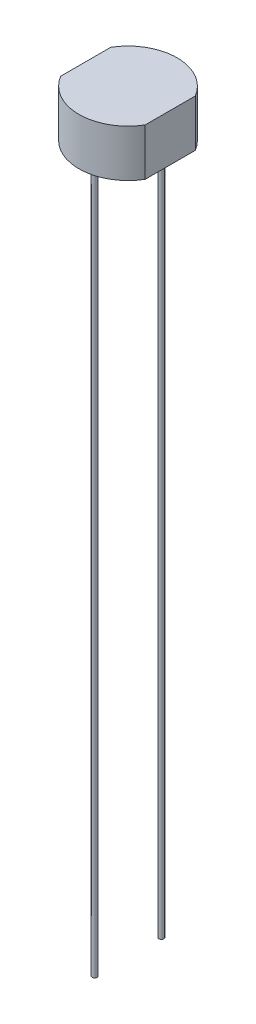
from build123d import *

# Parameters (mm, degrees)
BOSS_EXTRUDE1_DEPTH = 2.4
SKETCH2_R           = 0.125
BOSS_EXTRUDE2_DEPTH = 36


with BuildPart() as part:
    # Sketch1 → Boss-Extrude1 (new body)
    with BuildSketch(Plane(origin=(0, 0, 0), x_dir=(1, 0, 0), z_dir=(0, 1, 0))):
        with BuildLine():
            Line((-2.15, 1.275735082), (-2.15, -1.275735082))
            ThreePointArc((-2.15, -1.275735082), (0, -2.5), (2.15, -1.275735082))
            Line((2.15, -1.275735082), (2.15, 1.275735082))
            ThreePointArc((2.15, 1.275735082), (0, 2.5), (-2.15, 1.275735082))
        make_face()
    extrude(amount=BOSS_EXTRUDE1_DEPTH)

    # Sketch2 → Boss-Extrude2 (add)
    with BuildSketch(Plane(origin=(0, 0, 0), x_dir=(1, 0, 0), z_dir=(0, 1, 0))):
        with Locations((0, 1.7)):
            Circle(SKETCH2_R)
        with Locations((0, -1.7)):
            Circle(SKETCH2_R)
    extrude(amount=-BOSS_EXTRUDE2_DEPTH)


solid = part.part
